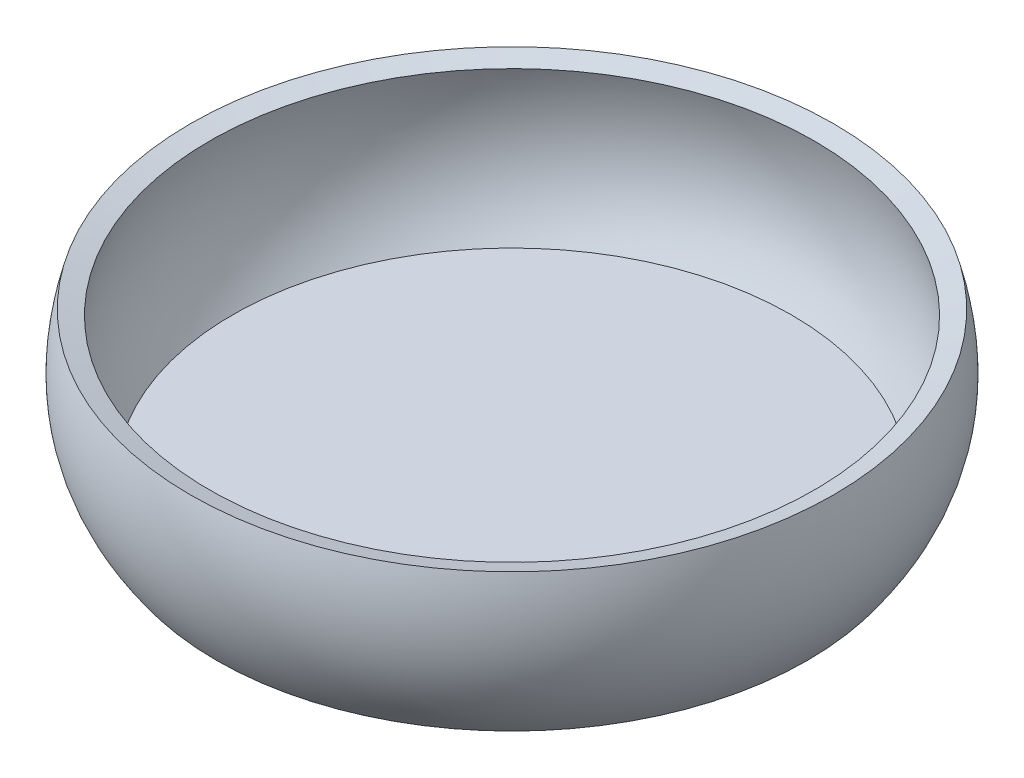
from build123d import *

# Parameters (mm, degrees)
SKETCH2_R          = 2.5
CUT_EXTRUDE2_DEPTH = 22


with BuildPart() as part:
    # Sketch1 → Revolve1 (revolve)
    with BuildSketch(Plane.XY):
        with BuildLine():
            add(Edge.make_bspline(
                [(51.158289136, 25.550050858), (54.407489378, 26.45683456)],
                knots=[0, 0, 1, 1], degree=1))
            add(Edge.make_bspline(
                [(50, 0), (58.550029809, 11.613224852), (54.407489378, 26.45683456)],
                knots=[0, 0, 0, 1, 1, 1], degree=2))
            Line((50, 0), (0, 0))
            Line((0, 0), (0, 2))
            Line((0, 2), (47.283465646, 2))
            add(Edge.make_bspline(
                [(47.283465646, 2), (50.153442659, 5.914089702), (52.221306271, 12.924512735), (52.569955472, 20.441362346), (51.158289136, 25.550050858)],
                knots=[0, 0, 0, 0.375, 0.625, 1, 1, 1], degree=2))
        make_face()
    revolve(axis=Axis((0, 0, 0), (0, 1, 0)))

    # Sketch2 → Cut-Extrude2 (cut)
    with BuildSketch(Plane.XZ):
        with Locations((25.596451493, 20.026773853)):
            Circle(SKETCH2_R)
        with Locations((17.720620264, 13.864689591)):
            Circle(SKETCH2_R)
    extrude(amount=-CUT_EXTRUDE2_DEPTH, mode=Mode.SUBTRACT)


solid = part.part
